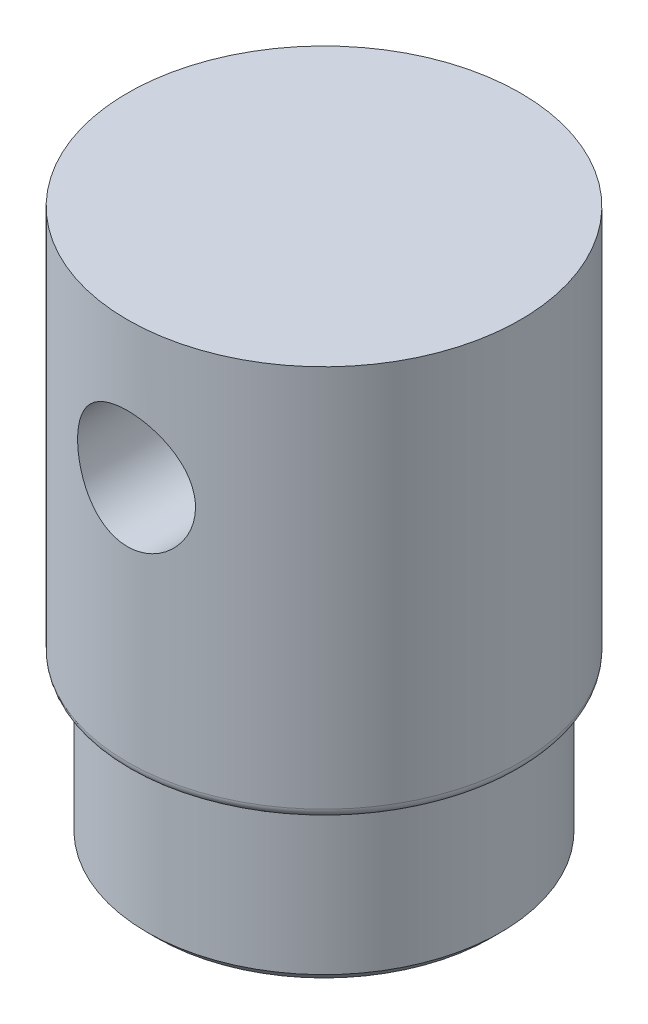
from build123d import *

# Parameters (mm, degrees)
SKETCH_1_R               = 10
EXTRUDE_1_DEPTH          = 20
SKETCH_2_R               = 9
EXTRUDE_2_DEPTH          = 8
SKETCH_3_R               = 3
CUT_EXTRUDE_1_DEPTH      = 11
CUT_EXTRUDE_1_DEPTH_BACK = 11
FILLET_1_R               = 0.5
CHAMFER_1_SIZE           = 0.5


with BuildPart() as part:
    # 草图1 → 凸台-拉伸1 (new body)
    with BuildSketch(Plane(origin=(0, 0, 0), x_dir=(1, 0, 0), z_dir=(0, 1, 0))):
        Circle(SKETCH_1_R)
    extrude(amount=EXTRUDE_1_DEPTH)

    # 草图2 → 凸台-拉伸2 (add)
    with BuildSketch(Plane.XZ):
        Circle(SKETCH_2_R)
    extrude(amount=EXTRUDE_2_DEPTH)

    # 草图3 → 切除-拉伸1 (cut, two sides)
    with BuildSketch(Plane.XY) as cut_extrude_1_sk:
        with Locations((0, 13)):
            Circle(SKETCH_3_R)
    extrude(amount=CUT_EXTRUDE_1_DEPTH, mode=Mode.SUBTRACT)
    extrude(cut_extrude_1_sk.sketch, amount=-CUT_EXTRUDE_1_DEPTH_BACK, mode=Mode.SUBTRACT)

    # 圆角1
    fillet_1_edges = [part.edges().sort_by_distance(p)[0] for p in [
        (-10, 0, 0),
    ]]
    fillet(fillet_1_edges, radius=FILLET_1_R)

    # 倒角1
    chamfer_1_edges = [part.edges().sort_by_distance(p)[0] for p in [
        (-9, -8, 0),
    ]]
    chamfer(chamfer_1_edges, length=CHAMFER_1_SIZE)


solid = part.part
